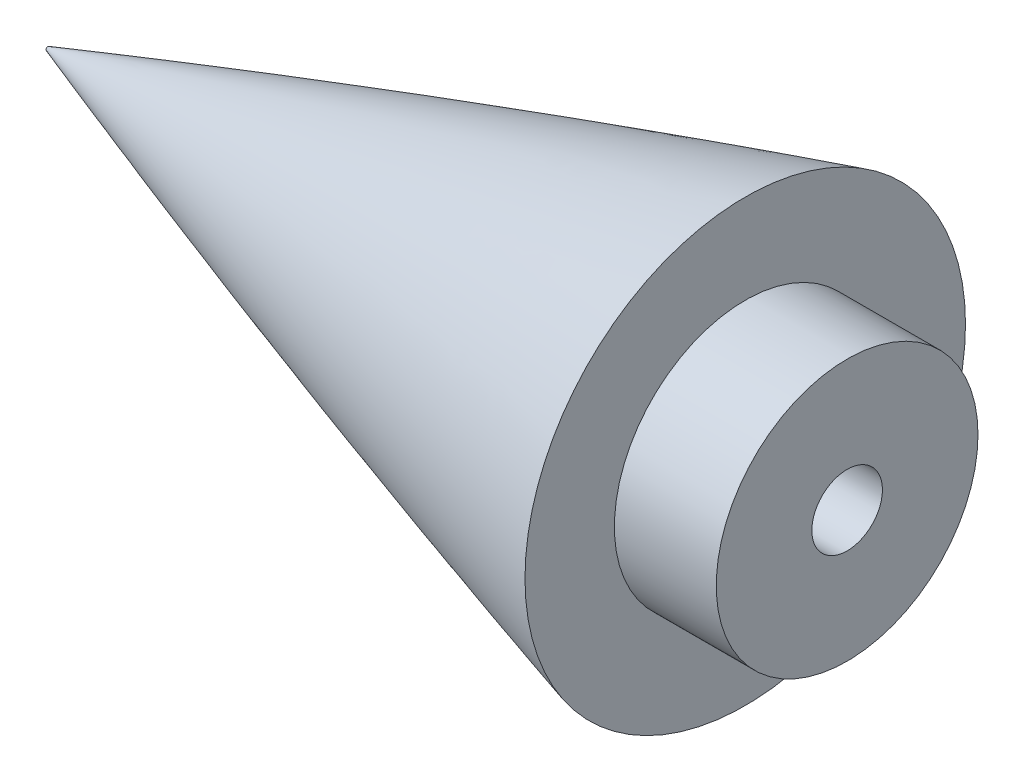
from build123d import *

# Parameters (mm, degrees)
SKETCH2_W                   = 266.7
SKETCH2_H                   = 127
SKETCH2_W_2                 = 4.523471484
SKETCH2_H_2                 = 5.51968765
CUT_EXTRUDE1_DEPTH          = 52.104787934
CUT_EXTRUDE1_DEPTH_BACK     = 52.104787934
SKETCH3_R                   = 9.4615
BOSS_EXTRUDE1_DEPTH         = 7.366
F_1_4_20_TAPPED_HOLE1_D     = 5.1054
F_1_4_20_TAPPED_HOLE1_DEPTH = 25.4
F_1_4_20_TAPPED_HOLE1_TIP   = 1.533816902


with BuildPart() as part:
    # Sketch1 → Revolve1 (revolve)
    with BuildSketch(Plane.XY):
        with BuildLine():
            Line((304.8, 51.104787834), (304.8, 0))
            Line((304.8, 0), (0, 0))
            add(Edge.make_bspline(
                [(0, 0), (33.866666667, 11.685111304), (67.733333333, 21.735698196), (101.6, 30.235154067), (135.466666666, 37.244703775), (169.333333333, 42.80972925), (203.2, 46.96249326), (237.066666666, 49.724027415), (270.933333333, 51.104777124), (304.8, 51.104787834)],
                knots=[0.079928624, 0.079928624, 0.079928624, 0.079928624, 0.079928624, 0.079928624, 0.079928624, 0.079928624, 0.079928624, 0.079928624, 0.916357148, 0.916357148, 0.916357148, 0.916357148, 0.916357148, 0.916357148, 0.916357148, 0.916357148, 0.916357148, 0.916357148], degree=9))
        make_face()
    revolve(axis=Axis((0, 0, 0), (1, 0, 0)))

    # Sketch2 → Cut-Extrude1 (cut, two sides)
    with BuildSketch(Plane.XY) as cut_extrude1_sk:
        with Locations((184.15, 0)):
            Rectangle(SKETCH2_W, SKETCH2_H)
        with Locations((-1.880735742, 0)):
            Rectangle(SKETCH2_W_2, SKETCH2_H_2)
    extrude(amount=CUT_EXTRUDE1_DEPTH, mode=Mode.SUBTRACT)
    extrude(cut_extrude1_sk.sketch, amount=-CUT_EXTRUDE1_DEPTH_BACK, mode=Mode.SUBTRACT)

    # Sketch3 → Boss-Extrude1 (add)
    with BuildSketch(Plane(origin=(50.8, 0, 0), x_dir=(0, 0, -1), z_dir=(1, 0, 0))):
        Circle(SKETCH3_R)
    extrude(amount=BOSS_EXTRUDE1_DEPTH)

    # 1/4-20 Tapped Hole1
    with Locations(Plane(origin=(58.166, 0, 0), x_dir=(0, 0, -1), z_dir=(1, 0, 0))):
        with Locations((0, 0)):
            Hole(F_1_4_20_TAPPED_HOLE1_D / 2, depth=F_1_4_20_TAPPED_HOLE1_DEPTH)
            with Locations((0, 0, -(F_1_4_20_TAPPED_HOLE1_DEPTH + F_1_4_20_TAPPED_HOLE1_TIP / 2))):  # 118° drill point
                Cone(0, F_1_4_20_TAPPED_HOLE1_D / 2, F_1_4_20_TAPPED_HOLE1_TIP, mode=Mode.SUBTRACT)


solid = part.part
